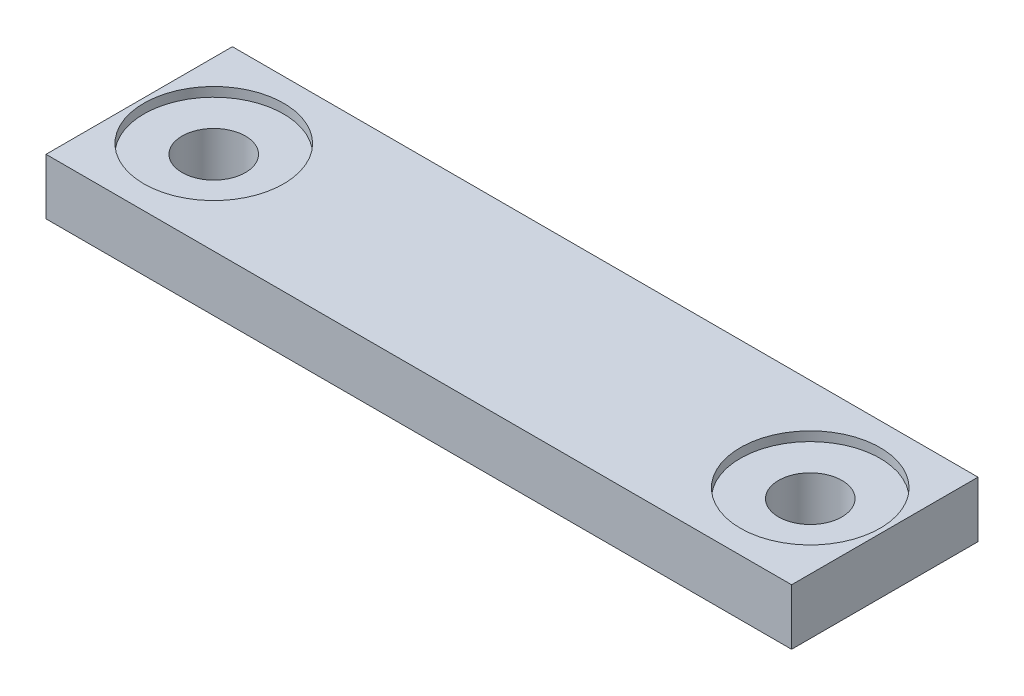
from build123d import *

# Parameters (mm, degrees)
SKETCH1_W                                        = 40
SKETCH1_H                                        = 10
BOSS_EXTRUDE1_DEPTH                              = 3
CBORE_FOR_M3_PAN_HEAD_MACHINE_SCREW1_D           = 3.4
CBORE_FOR_M3_PAN_HEAD_MACHINE_SCREW1_DEPTH       = 3
CBORE_FOR_M3_PAN_HEAD_MACHINE_SCREW1_CBORE_D     = 7.5
CBORE_FOR_M3_PAN_HEAD_MACHINE_SCREW1_CBORE_DEPTH = 0.5


with BuildPart() as part:
    # Sketch1 → Boss-Extrude1 (new body)
    with BuildSketch(Plane(origin=(0, 0, 0), x_dir=(1, 0, 0), z_dir=(0, 1, 0))):
        with Locations((20, -5)):
            Rectangle(SKETCH1_W, SKETCH1_H)
    extrude(amount=-BOSS_EXTRUDE1_DEPTH)

    # CBORE for M3 Pan Head Machine Screw1
    with Locations(Plane(origin=(0, 0, 0), x_dir=(1, 0, 0), z_dir=(0, 1, 0))):
        with Locations((4, -5), (36, -5)):
            CounterBoreHole(CBORE_FOR_M3_PAN_HEAD_MACHINE_SCREW1_D / 2, CBORE_FOR_M3_PAN_HEAD_MACHINE_SCREW1_CBORE_D / 2, CBORE_FOR_M3_PAN_HEAD_MACHINE_SCREW1_CBORE_DEPTH, depth=CBORE_FOR_M3_PAN_HEAD_MACHINE_SCREW1_DEPTH)


solid = part.part
